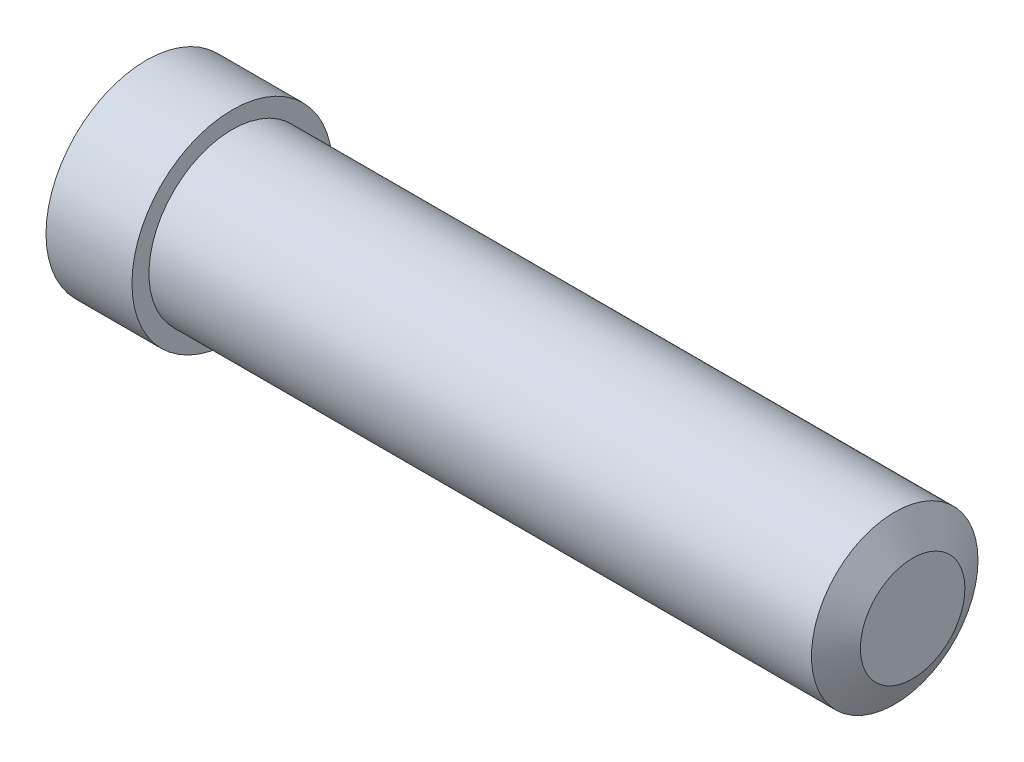
from build123d import *

# Parameters (mm, degrees)
SKETCH1_R           = 1.4224
BOSS_EXTRUDE1_DEPTH = 1.2192
SKETCH2_R           = 1.1811
BOSS_EXTRUDE2_DEPTH = 9.652
CHAMFER1_SIZE       = 0.254
CHAMFER1_SIZE2      = 0.439940905


with BuildPart() as part:
    # Sketch1 → Boss-Extrude1 (new body)
    with BuildSketch(Plane(origin=(0, 0, 0), x_dir=(0, 0, -1), z_dir=(1, 0, 0))):
        Circle(SKETCH1_R)
    extrude(amount=BOSS_EXTRUDE1_DEPTH)

    # Sketch2 → Boss-Extrude2 (add)
    with BuildSketch(Plane(origin=(1.2192, 0, 0), x_dir=(0, 0, -1), z_dir=(1, 0, 0))):
        Circle(SKETCH2_R)
    extrude(amount=BOSS_EXTRUDE2_DEPTH)

    # Chamfer1
    chamfer1_edges = [part.edges().sort_by_distance(p)[0] for p in [
        (10.8712, 0, 1.1811),
    ]]
    chamfer1_side = [part.faces().sort_by_distance(p)[0] for p in [
        (6.0452, 0, 1.1811),
    ]]
    chamfer(chamfer1_edges, length=CHAMFER1_SIZE, length2=CHAMFER1_SIZE2, reference=chamfer1_side[0])


solid = part.part
